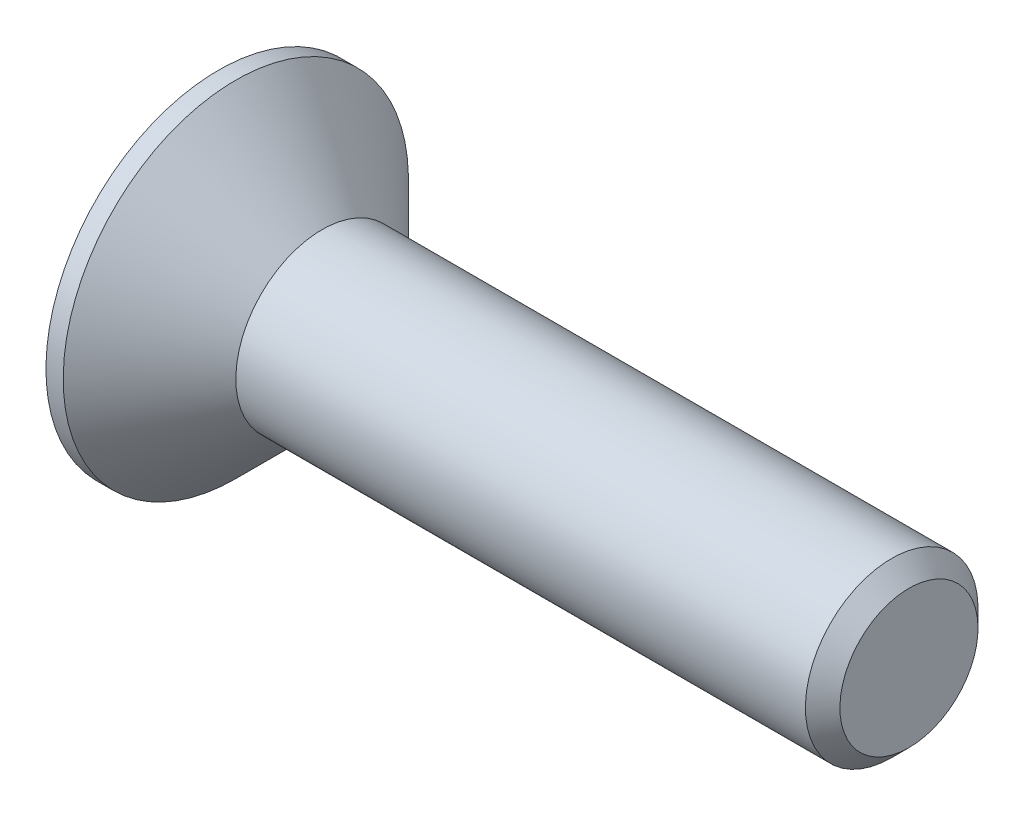
from build123d import *

# Parameters (mm, degrees)
CHAMFER1_SIZE      = 0.2
CUT_EXTRUDE1_DEPTH = 0.75


with BuildPart() as part:
    # Sketch1 → Revolve1 (revolve)
    with BuildSketch(Plane.XY):
        Polygon((0, 1), (-1, 2), (-1.2, 2), (-1.2, 0), (6.8, 0), (6.8, 1), align=None)
    revolve(axis=Axis((-1.2, 0, 0), (1, 0, 0)))

    # Chamfer1
    chamfer1_edges = [part.edges().sort_by_distance(p)[0] for p in [
        (6.8, -1, 0),
    ]]
    chamfer(chamfer1_edges, length=CHAMFER1_SIZE)

    # Sketch2 → Cut-Extrude1 (cut)
    with BuildSketch(Plane.ZY.offset(1.2)):
        Polygon((-0.75055535, 0), (-0.375277675, -0.65), (0.375277675, -0.65), (0.75055535, 0), (0.375277675, 0.65), (-0.375277675, 0.65), align=None)
    extrude(amount=-CUT_EXTRUDE1_DEPTH, mode=Mode.SUBTRACT)


solid = part.part
